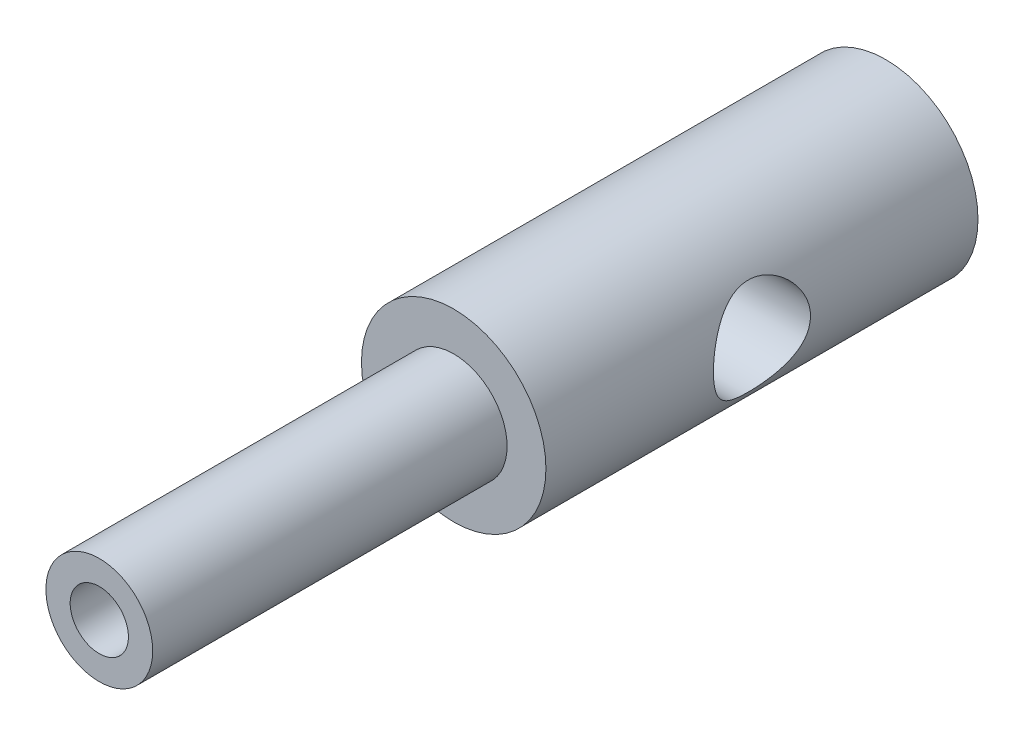
from build123d import *

# Parameters (mm, degrees)
SKETCH2_R               = 2.54
CUT_EXTRUDE2_DEPTH      = 5.8260001
CUT_EXTRUDE2_DEPTH_BACK = 5.8260001


with BuildPart() as part:
    # Sketch1 → Revolve1 (revolve)
    with BuildSketch(Plane(origin=(0, 0, 0), x_dir=(0, 0, -1), z_dir=(1, 0, 0))):
        with BuildLine():
            Line((2.54, 0), (11.303, 0))
            Line((11.303, 0), (12.319, 0))
            ThreePointArc((12.319, 0), (12.085657597, 2.470822652), (11.303, 4.826))
            Line((11.303, 4.826), (-11.303, 4.826))
            Line((-11.303, 4.826), (-11.303, 2.794))
            Line((-11.303, 2.794), (-29.845, 2.794))
            Line((-29.845, 2.794), (-29.845, 1.524))
            Line((-29.845, 1.524), (-11.303, 1.524))
            Line((-11.303, 1.524), (-11.303, 0))
            Line((-11.303, 0), (-2.54, 0))
            ThreePointArc((-2.54, 0), (0, 2.54), (2.54, 0))
        make_face()
    revolve(axis=Axis((0, 0, 36.613472311), (0, 0, -1)))

    # Sketch2 → Cut-Extrude2 (cut, two sides)
    with BuildSketch(Plane(origin=(0, 0, 0), x_dir=(0, 0, -1), z_dir=(1, 0, 0))) as cut_extrude2_sk:
        Circle(SKETCH2_R)
    extrude(amount=CUT_EXTRUDE2_DEPTH, mode=Mode.SUBTRACT)
    extrude(cut_extrude2_sk.sketch, amount=-CUT_EXTRUDE2_DEPTH_BACK, mode=Mode.SUBTRACT)


solid = part.part
